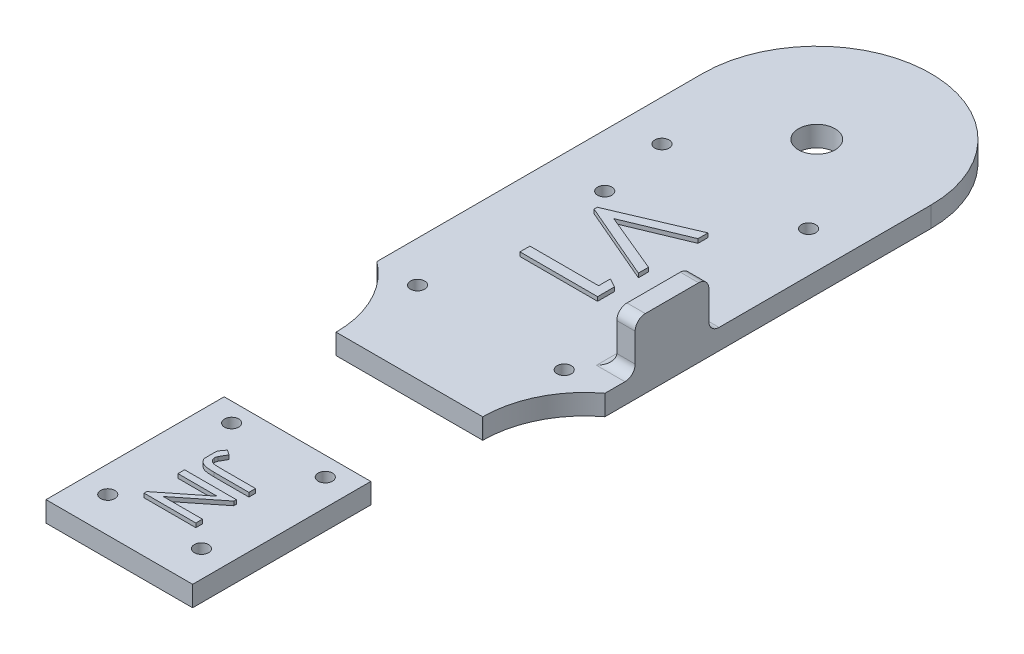
from build123d import *

# Parameters (mm, degrees)
SKETCH2_R           = 1.75
BOSS_EXTRUDE5_DEPTH = 5
BOSS_EXTRUDE6_DEPTH = 6
SKETCH3_W           = 4.5
SKETCH3_H           = 18.093056915
BOSS_EXTRUDE7_DEPTH = 12
FILLET1_R           = 2.5


with BuildPart() as part:
    # Sketch2 → Boss-Extrude5 (new body)
    with BuildSketch(Plane(origin=(0, 0, 0), x_dir=(1, 0, 0), z_dir=(0, 1, 0))):
        with BuildLine():
            Line((-17.126311361, -31.616311361), (-17.126311361, -75.356311361))
            Line((-17.126311361, -75.356311361), (-5.464372379, -75.356311361))
            Line((-5.464372379, -75.356311361), (-5.464372379, -62.929901105))
            Line((-5.464372379, -62.929901105), (-5.464372379, -62.26335463))
            Line((-5.464372379, -62.26335463), (-5.464372379, -54.626054951))
            Line((-5.464372379, -54.626054951), (-5.464372379, -52.997849822))
            Line((-5.464372379, -52.997849822), (-5.464372379, -48.239212878))
            add(Edge.make_bspline(
                [(-5.464372379, -48.239212878), (-5.479308008, -48.209347326), (-5.526944327, -48.109888501), (-5.598562611, -47.934535736), (-5.665278067, -47.707111583), (-5.722418695, -47.469664507), (-5.777392685, -47.132561506), (-5.789435468, -46.872012813), (-5.790013405, -46.696187162)],
                knots=[0.75048722, 0.75048722, 0.75048722, 0.75048722, 0.766195838, 0.802355905, 0.839467772, 0.877601694, 0.917224315, 1, 1, 1, 1], degree=3))
            add(Edge.make_bspline(
                [(-5.790013405, -46.696187162), (-5.791830358, -46.443369479), (-5.752256309, -46.064323872), (-5.630108747, -45.570490958), (-5.535850567, -45.305024528), (-5.474802855, -45.162981053), (-5.464372379, -45.139410724)],
                knots=[0, 0, 0, 0, 0.213832278, 0.321108442, 0.430122341, 0.45193341, 0.45193341, 0.45193341, 0.45193341], degree=3))
            Line((-5.464372379, -45.139410724), (-5.464372379, -31.616311361))
            Line((-5.464372379, -31.616311361), (-17.126311361, -31.616311361))
        make_face()
        with Locations((-10.626311361, -66.696311361)):
            Circle(SKETCH2_R, mode=Mode.SUBTRACT)
        with Locations((-10.626311361, -36.286311361)):
            Circle(SKETCH2_R, mode=Mode.SUBTRACT)
        with BuildLine():
            Line((-5.464372379, -62.929901105), (-5.464372379, -75.356311361))
            Line((-5.464372379, -75.356311361), (18.873688639, -75.356311361))
            Line((18.873688639, -75.356311361), (18.873688639, -31.616311361))
            Line((18.873688639, -31.616311361), (-5.464372379, -31.616311361))
            Line((-5.464372379, -31.616311361), (-5.464372379, -45.139410724))
            add(Edge.make_bspline(
                [(-5.464372379, -45.139410724), (-5.41828807, -45.035271445), (-5.296718229, -44.792277229), (-4.945206965, -44.247543692), (-4.608474951, -43.832316799), (-4.355157635, -43.554260079)],
                knots=[0.45193341, 0.45193341, 0.45193341, 0.45193341, 0.548299864, 0.681572511, 1, 1, 1, 1], degree=3))
            Line((-4.355157635, -43.554260079), (-3.184885199, -44.360730431))
            add(Edge.make_bspline(
                [(-3.184885199, -44.360730431), (-3.299202447, -44.541589378), (-3.459903064, -44.805093082), (-3.661450848, -45.143322346), (-3.790371764, -45.367230916), (-3.902981676, -45.571332012), (-4.029665545, -45.800928622), (-4.10835225, -45.966968377), (-4.156720135, -46.070345816)],
                knots=[0, 0, 0, 0, 0.32618873, 0.470537175, 0.600272768, 0.720074035, 0.825942194, 1, 1, 1, 1], degree=3))
            add(Edge.make_bspline(
                [(-4.156720135, -46.070345816), (-4.209286382, -46.184077533), (-4.286247323, -46.404049964), (-4.325967125, -46.634236156), (-4.324628789, -46.741980431)],
                knots=[0, 0, 0, 0, 0.538548713, 1, 1, 1, 1], degree=3))
            add(Edge.make_bspline(
                [(-4.324628789, -46.741980431), (-4.324559221, -46.891783443), (-4.290667843, -47.117141621), (-4.167635974, -47.393772358), (-4.044150741, -47.588920682), (-3.887300055, -47.764285737), (-3.698888458, -47.910877403), (-3.487752607, -48.034615376), (-3.286355624, -48.109906835), (-3.101832091, -48.161844908), (-2.929102182, -48.188504454), (-2.72685785, -48.218954398), (-2.492989027, -48.236143316), (-2.228537136, -48.255203457), (-1.813788183, -48.271918849), (-1.487184361, -48.276087959), (-1.259023821, -48.276054951)],
                knots=[0, 0, 0, 0, 0.116093762, 0.173422383, 0.233342697, 0.29424406, 0.354533692, 0.417481441, 0.482953194, 0.520380905, 0.565714452, 0.618080332, 0.678708602, 0.747141738, 0.823369406, 1, 1, 1, 1], degree=3))
            Line((-1.259023821, -48.276054951), (7.235627621, -48.276054951))
            Line((7.235627621, -48.276054951), (7.235627621, -49.904260079))
            Line((7.235627621, -49.904260079), (-1.289552667, -49.904260079))
            add(Edge.make_bspline(
                [(-1.289552667, -49.904260079), (-1.586310839, -49.901182176), (-2.014411, -49.900143194), (-2.559462693, -49.863595429), (-2.915754705, -49.830541303), (-3.236953259, -49.791791145), (-3.523261343, -49.741237263), (-3.773600929, -49.681488083), (-4.058575491, -49.587069258), (-4.376573461, -49.433687342), (-4.72160044, -49.195875985), (-5.02821201, -48.899206761), (-5.251787885, -48.611218592), (-5.389284918, -48.383433866), (-5.444864563, -48.278221057), (-5.464372379, -48.239212878)],
                knots=[0, 0, 0, 0, 0.139694311, 0.201274236, 0.256981351, 0.308058655, 0.353456894, 0.393717345, 0.429048902, 0.494549285, 0.559079856, 0.625401593, 0.694521248, 0.729969783, 0.75048722, 0.75048722, 0.75048722, 0.75048722], degree=3))
            Line((-5.464372379, -48.239212878), (-5.464372379, -52.997849822))
            Line((-5.464372379, -52.997849822), (7.235627621, -52.997849822))
            Line((7.235627621, -52.997849822), (7.235627621, -53.600794534))
            Line((7.235627621, -53.600794534), (-2.414031834, -61.301695976))
            Line((-2.414031834, -61.301695976), (7.235627621, -61.301695976))
            Line((7.235627621, -61.301695976), (7.235627621, -62.929901105))
            Line((7.235627621, -62.929901105), (-5.464372379, -62.929901105))
        make_face()
        with Locations((12.373688639, -66.696311361)):
            Circle(SKETCH2_R, mode=Mode.SUBTRACT)
        with Locations((12.373688639, -36.286311361)):
            Circle(SKETCH2_R, mode=Mode.SUBTRACT)
        with BuildLine():
            Line((-17.126311361, -4.126311361), (-17.126311361, -4.136311361))
            Line((-17.126311361, -4.136311361), (-10.626311361, -4.136311361))
            Line((-10.626311361, -4.136311361), (-10.626311361, 34.51195787))
            Line((-10.626311361, 34.51195787), (-10.626311361, 36.954265562))
            Line((-10.626311361, 36.954265562), (-10.626311361, 52.69570186))
            Line((-10.626311361, 52.69570186), (-10.626311361, 53.478003543))
            Line((-10.626311361, 53.478003543), (-10.626311361, 95.873688639))
            Line((-10.626311361, 95.873688639), (-27.126311361, 95.873688639))
            Line((-27.126311361, 95.873688639), (-27.126311361, 15.874142351))
            ThreePointArc((-27.126311361, 15.874142351), (-19.765625932, 7.054231433), (-17.126311361, -4.126311361))
        make_face()
        with Locations((-17.126311361, 15.863688639)):
            Circle(SKETCH2_R, mode=Mode.SUBTRACT)
        with Locations((-14.126311361, 58.813688639)):
            Circle(SKETCH2_R, mode=Mode.SUBTRACT)
        with Locations((-17.126311361, 75.863688639)):
            Circle(SKETCH2_R, mode=Mode.SUBTRACT)
        with BuildLine():
            Line((-10.626311361, 34.51195787), (-10.626311361, -4.136311361))
            Line((-10.626311361, -4.136311361), (18.873688639, -4.136311361))
            Line((18.873688639, -4.136311361), (18.873688639, -4.126765073))
            ThreePointArc((18.873688639, -4.126765073), (21.51300321, 7.053777721), (28.873688639, 15.873688639))
            Line((28.873688639, 15.873688639), (28.873688639, 95.873688639))
            Line((28.873688639, 95.873688639), (5.373688639, 95.873688639))
            ThreePointArc((5.373688639, 95.873688639), (0.873688639, 91.373688639), (-3.626311361, 95.873688639))
            Line((-3.626311361, 95.873688639), (-10.626311361, 95.873688639))
            Line((-10.626311361, 95.873688639), (-10.626311361, 53.478003543))
            Line((-10.626311361, 53.478003543), (8.423688639, 61.621573254))
            Line((8.423688639, 61.621573254), (8.423688639, 59.164001139))
            Line((8.423688639, 59.164001139), (-6.188180351, 53.084944649))
            Line((-6.188180351, 53.084944649), (8.423688639, 47.009704264))
            Line((8.423688639, 47.009704264), (8.423688639, 44.525419408))
            Line((8.423688639, 44.525419408), (-10.626311361, 52.69570186))
            Line((-10.626311361, 52.69570186), (-10.626311361, 36.954265562))
            Line((-10.626311361, 36.954265562), (6.225611716, 36.954265562))
            Line((6.225611716, 36.954265562), (6.225611716, 39.885034793))
            Line((6.225611716, 39.885034793), (8.423688639, 38.656248735))
            Line((8.423688639, 38.656248735), (8.423688639, 34.51195787))
            Line((8.423688639, 34.51195787), (-10.626311361, 34.51195787))
        make_face()
        with Locations((18.873688639, 15.863688639)):
            Circle(SKETCH2_R, mode=Mode.SUBTRACT)
        with Locations((18.873688639, 75.863688639)):
            Circle(SKETCH2_R, mode=Mode.SUBTRACT)
        Polygon((-5.464372379, -54.626054951), (-5.464372379, -62.26335463), (4.159846371, -54.626054951), align=None)
        with BuildLine():
            ThreePointArc((28.873688639, 95.873688639), (0.873688639, 123.873688639), (-27.126311361, 95.873688639))
            Line((-27.126311361, 95.873688639), (-10.626311361, 95.873688639))
            Line((-10.626311361, 95.873688639), (-3.626311361, 95.873688639))
            ThreePointArc((-3.626311361, 95.873688639), (0.873688639, 100.373688639), (5.373688639, 95.873688639))
            Line((5.373688639, 95.873688639), (28.873688639, 95.873688639))
        make_face()
    extrude(amount=BOSS_EXTRUDE5_DEPTH)

    # Sketch2_10 → Boss-Extrude6 (add)
    with BuildSketch(Plane(origin=(0, 0, 0), x_dir=(1, 0, 0), z_dir=(0, 1, 0))):
        Polygon((-5.464372379, -62.26335463), (-5.464372379, -62.929901105), (7.235627621, -62.929901105), (7.235627621, -61.301695976), (-2.414031834, -61.301695976), (7.235627621, -53.600794534), (7.235627621, -52.997849822), (-5.464372379, -52.997849822), (-5.464372379, -54.626054951), (4.159846371, -54.626054951), align=None)
        with BuildLine():
            add(Edge.make_bspline(
                [(-5.464372379, -45.139410724), (-5.41828807, -45.035271445), (-5.296718229, -44.792277229), (-4.945206965, -44.247543692), (-4.608474951, -43.832316799), (-4.355157635, -43.554260079)],
                knots=[0.45193341, 0.45193341, 0.45193341, 0.45193341, 0.548299864, 0.681572511, 1, 1, 1, 1], degree=3))
            Line((-5.464372379, -45.139410724), (-5.464372379, -48.239212878))
            add(Edge.make_bspline(
                [(-1.289552667, -49.904260079), (-1.586310839, -49.901182176), (-2.014411, -49.900143194), (-2.559462693, -49.863595429), (-2.915754705, -49.830541303), (-3.236953259, -49.791791145), (-3.523261343, -49.741237263), (-3.773600929, -49.681488083), (-4.058575491, -49.587069258), (-4.376573461, -49.433687342), (-4.72160044, -49.195875985), (-5.02821201, -48.899206761), (-5.251787885, -48.611218592), (-5.389284918, -48.383433866), (-5.444864563, -48.278221057), (-5.464372379, -48.239212878)],
                knots=[0, 0, 0, 0, 0.139694311, 0.201274236, 0.256981351, 0.308058655, 0.353456894, 0.393717345, 0.429048902, 0.494549285, 0.559079856, 0.625401593, 0.694521248, 0.729969783, 0.75048722, 0.75048722, 0.75048722, 0.75048722], degree=3))
            Line((-1.289552667, -49.904260079), (7.235627621, -49.904260079))
            Line((7.235627621, -49.904260079), (7.235627621, -48.276054951))
            Line((7.235627621, -48.276054951), (-1.259023821, -48.276054951))
            add(Edge.make_bspline(
                [(-4.324628789, -46.741980431), (-4.324559221, -46.891783443), (-4.290667843, -47.117141621), (-4.167635974, -47.393772358), (-4.044150741, -47.588920682), (-3.887300055, -47.764285737), (-3.698888458, -47.910877403), (-3.487752607, -48.034615376), (-3.286355624, -48.109906835), (-3.101832091, -48.161844908), (-2.929102182, -48.188504454), (-2.72685785, -48.218954398), (-2.492989027, -48.236143316), (-2.228537136, -48.255203457), (-1.813788183, -48.271918849), (-1.487184361, -48.276087959), (-1.259023821, -48.276054951)],
                knots=[0, 0, 0, 0, 0.116093762, 0.173422383, 0.233342697, 0.29424406, 0.354533692, 0.417481441, 0.482953194, 0.520380905, 0.565714452, 0.618080332, 0.678708602, 0.747141738, 0.823369406, 1, 1, 1, 1], degree=3))
            add(Edge.make_bspline(
                [(-4.156720135, -46.070345816), (-4.209286382, -46.184077533), (-4.286247323, -46.404049964), (-4.325967125, -46.634236156), (-4.324628789, -46.741980431)],
                knots=[0, 0, 0, 0, 0.538548713, 1, 1, 1, 1], degree=3))
            add(Edge.make_bspline(
                [(-3.184885199, -44.360730431), (-3.299202447, -44.541589378), (-3.459903064, -44.805093082), (-3.661450848, -45.143322346), (-3.790371764, -45.367230916), (-3.902981676, -45.571332012), (-4.029665545, -45.800928622), (-4.10835225, -45.966968377), (-4.156720135, -46.070345816)],
                knots=[0, 0, 0, 0, 0.32618873, 0.470537175, 0.600272768, 0.720074035, 0.825942194, 1, 1, 1, 1], degree=3))
            Line((-3.184885199, -44.360730431), (-4.355157635, -43.554260079))
        make_face()
        Polygon((-10.626311361, 36.954265562), (-10.626311361, 34.51195787), (8.423688639, 34.51195787), (8.423688639, 38.656248735), (6.225611716, 39.885034793), (6.225611716, 36.954265562), align=None)
        Polygon((-10.626311361, 53.478003543), (-10.626311361, 52.69570186), (8.423688639, 44.525419408), (8.423688639, 47.009704264), (-6.188180351, 53.084944649), (8.423688639, 59.164001139), (8.423688639, 61.621573254), align=None)
    extrude(amount=BOSS_EXTRUDE6_DEPTH)

    # Sketch3 → Boss-Extrude7 (add)
    with BuildSketch(Plane(origin=(0, 5, 0), x_dir=(1, 0, 0), z_dir=(0, 1, 0))):
        with Locations((26.623688639, 32.327214021)):
            Rectangle(SKETCH3_W, SKETCH3_H)
    extrude(amount=BOSS_EXTRUDE7_DEPTH)

    # Fillet1
    fillet1_edges = [part.edges().sort_by_distance(p)[0] for p in [
        (26.623688639, 5, -41.373742478),
        (24.373688639, 5, -32.32721402),
        (26.623688639, 5, -23.280685563),
        (26.623688639, 17, -41.373742478),
        (26.623688639, 17, -23.280685563),
    ]]
    fillet(fillet1_edges, radius=FILLET1_R)


solid = part.part
